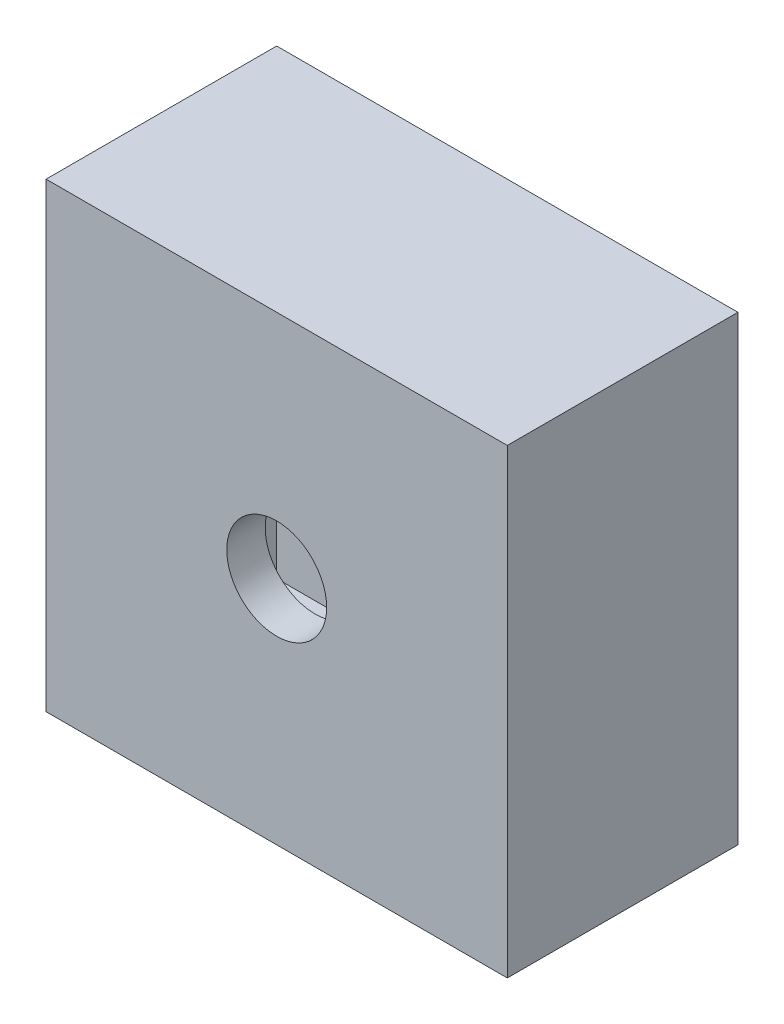
from build123d import *

# Parameters (mm, degrees)
SKETCH2_W           = 1200
SKETCH2_H           = 1200
BOSS_EXTRUDE1_DEPTH = 600
SHELL1_T            = -100
SKETCH3_W           = 1200
SKETCH3_H           = 1200
BOSS_EXTRUDE2_DEPTH = 100
SKETCH4_R           = 130
CUT_EXTRUDE1_DEPTH  = 601
SKETCH5_W           = 130
SKETCH5_H           = 130
CUT_EXTRUDE2_DEPTH  = 150
CIRPATTERN2_COUNT   = 4


with BuildPart() as part:
    # Sketch2 → Boss-Extrude1 (new body)
    with BuildSketch(Plane.XY):
        Rectangle(SKETCH2_W, SKETCH2_H)
    extrude(amount=BOSS_EXTRUDE1_DEPTH)

    # Shell1
    shell1_openings = [part.faces().sort_by_distance(p)[0] for p in [
        (0, 0, 600),
    ]]
    offset(amount=SHELL1_T, openings=shell1_openings, kind=Kind.INTERSECTION)

    # Sketch3 → Boss-Extrude2 (add)
    with BuildSketch(Plane.XY.offset(600)):
        Rectangle(SKETCH3_W, SKETCH3_H)
    extrude(amount=-BOSS_EXTRUDE2_DEPTH)

    # Sketch4 → Cut-Extrude1 (cut, through all)
    with BuildSketch(Plane.XY):
        Circle(SKETCH4_R)
    extrude(amount=CUT_EXTRUDE1_DEPTH, mode=Mode.SUBTRACT)

    # Sketch5 → Cut-Extrude2 (cut)
    with BuildSketch(Plane(origin=(0, 0, 0), x_dir=(-1, 0, 0), z_dir=(0, 0, -1))):
        with Locations((-310, 0)):
            Rectangle(SKETCH5_W, SKETCH5_H)
    cut_extrude2 = extrude(amount=-CUT_EXTRUDE2_DEPTH, mode=Mode.SUBTRACT)

    # CirPattern2: Cut-Extrude2 ×4 about axis
    cirpattern2_axis = Axis((0, 0, 0), (0, 0, 1))
    for i in range(1, CIRPATTERN2_COUNT):
        add(cut_extrude2.rotate(cirpattern2_axis, i * 360 / CIRPATTERN2_COUNT), mode=Mode.SUBTRACT)


solid = part.part
